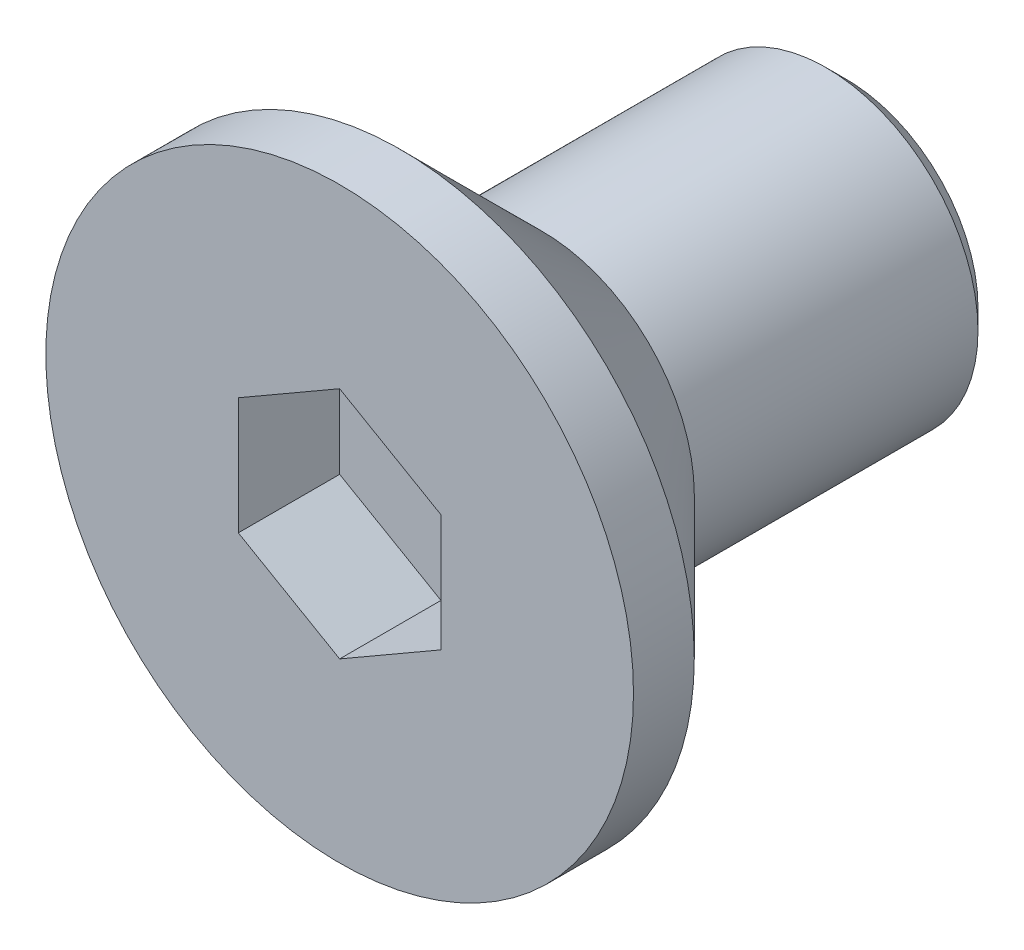
from build123d import *

# Parameters (mm, degrees)
SCHNITT_LINEAR_AUSTRAGEN1_DEPTH = 1
FASE1_SIZE                      = 0.2


with BuildPart() as part:
    # Skizze1 → Rotation1 (revolve)
    with BuildSketch(Plane(origin=(0, 0, 0), x_dir=(0, 0, -1), z_dir=(1, 0, 0))):
        Polygon((0, 0), (0, 2.9), (0.6, 2.9), (2, 1.5), (5, 1.5), (5, 0), align=None)
    revolve(axis=Axis((0, 0, 31.763581507), (0, 0, -1)))

    # Skizze3 → Schnitt-Linear austragen1 (cut)
    with BuildSketch(Plane.XY):
        Polygon((1, -0.577350269), (1, 0.577350269), (0, 1.154700538), (-1, 0.577350269), (-1, -0.577350269), (0, -1.154700538), align=None)
    extrude(amount=-SCHNITT_LINEAR_AUSTRAGEN1_DEPTH, mode=Mode.SUBTRACT)

    # Fase1
    fase1_edges = [part.edges().sort_by_distance(p)[0] for p in [
        (0, -1.5, -5),
    ]]
    chamfer(fase1_edges, length=FASE1_SIZE)


solid = part.part
